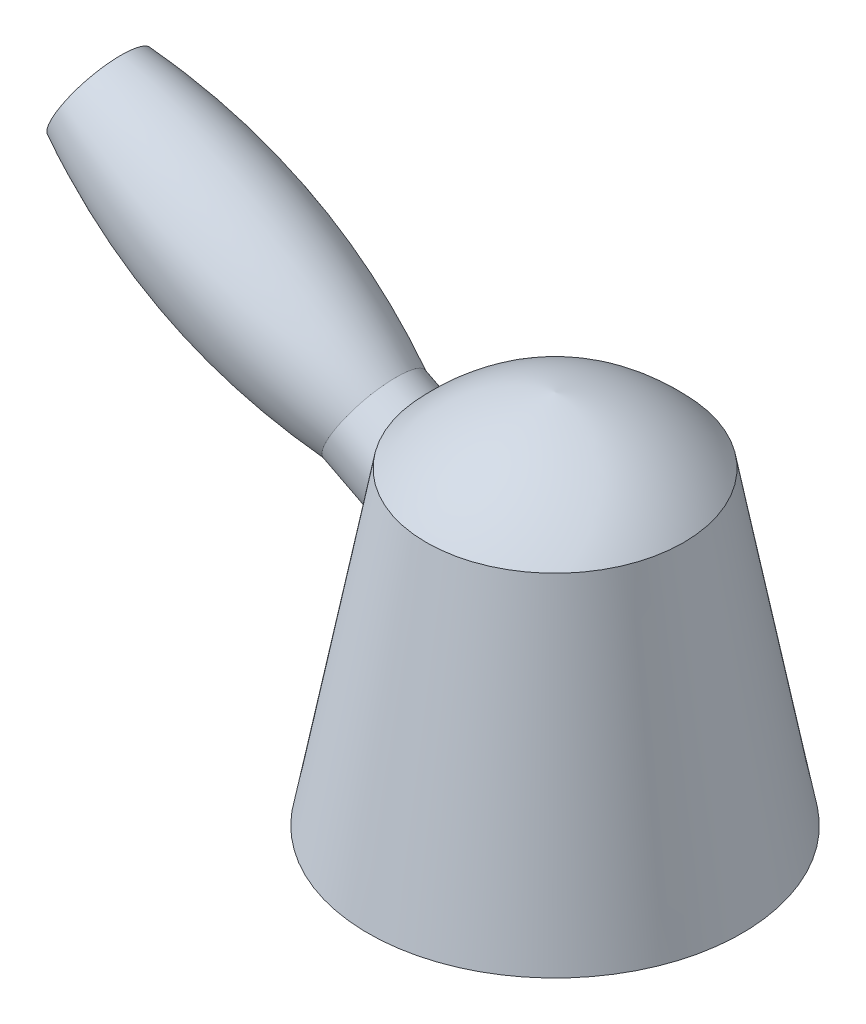
from build123d import *


with BuildPart() as part:
    # Sketch1 → Revolve2 (revolve)
    with BuildSketch(Plane.XY):
        with BuildLine():
            Line((-21.346613546, 51.322709163), (-31, 0))
            Line((-31, 0), (-13, 0))
            Line((-13, 0), (-13, 38))
            Line((-13, 38), (0, 38))
            Line((0, 38), (0, 62.22310757))
            add(Edge.make_bspline(
                [(-21.346613546, 51.322709163), (-12.732751992, 60.593465444), (0, 62.22310757)],
                knots=[0, 0, 0, 1, 1, 1], degree=2))
        make_face()
    revolve(axis=Axis((0, 62.22310757, 0), (0, -1, 0)))

    # Sketch3 → Revolve3 (revolve)
    with BuildSketch(Plane.XY):
        with BuildLine():
            Line((-19.124549702, 38.552742214), (-75.621657411, 67.624527958))
            Line((-75.621657411, 67.624527958), (-72.008511604, 74.646191148))
            add(Edge.make_bspline(
                [(-72.008511604, 74.646191148), (-46.325833762, 68.784299288), (-26.392991631, 51.173757302)],
                knots=[0, 0, 0, 1, 1, 1], degree=2))
            Line((-26.392991631, 51.173757302), (-15.511403895, 45.574405405))
            Line((-15.511403895, 45.574405405), (-19.124549702, 38.552742214))
        make_face()
    revolve(axis=Axis((-19.124549702, 38.552742214, 0), (-0.8891845276201251, 0.4575487688115606, 0)))


solid = part.part
